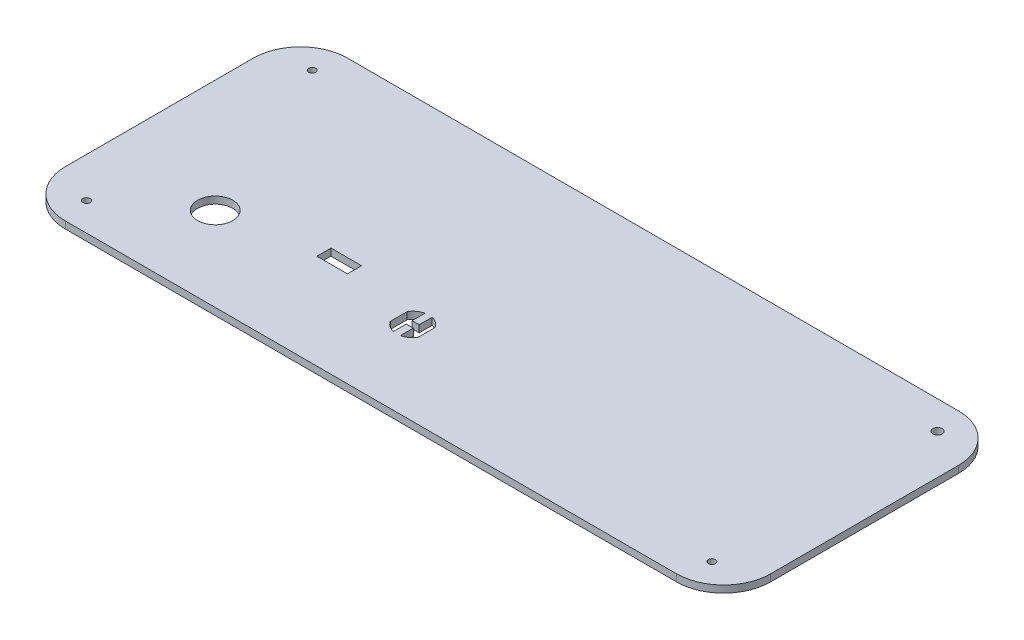
from build123d import *

# Parameters (mm, degrees)
SKETCH_2_W      = 300
SKETCH_2_H      = 120
SKETCH_2_R      = 1.5
SKETCH_2_R_2    = 2
SKETCH_2_R_3    = 7.5
SKETCH_2_W_2    = 13
SKETCH_2_H_2    = 6
EXTRUDE_1_DEPTH = 3
FILLET_1_R      = 20


with BuildPart() as part:
    # Эскиз2 → Бобышка-Вытянуть1 (new body)
    with BuildSketch(Plane(origin=(0, 0, 0), x_dir=(1, 0, 0), z_dir=(0, 1, 0))):
        with Locations((-150, 60)):
            Rectangle(SKETCH_2_W, SKETCH_2_H)
        with Locations((-283, 108)):
            Circle(SKETCH_2_R, mode=Mode.SUBTRACT)
        with Locations((-17, 108)):
            Circle(SKETCH_2_R_2, mode=Mode.SUBTRACT)
        with Locations((-17, 12)):
            Circle(SKETCH_2_R, mode=Mode.SUBTRACT)
        with Locations((-283, 12)):
            Circle(SKETCH_2_R, mode=Mode.SUBTRACT)
        with Locations((-252, 35.746485704)):
            Circle(SKETCH_2_R_3, mode=Mode.SUBTRACT)
        with Locations((-207, 43.496485704)):
            Rectangle(SKETCH_2_W_2, SKETCH_2_H_2, mode=Mode.SUBTRACT)
        with BuildLine():
            Line((-173.9, 39.324194468), (-173.9, 32.16877694))
            ThreePointArc((-173.9, 32.16877694), (-172.022697555, 30.140426091), (-169.5, 29.011502408))
            Line((-169.5, 29.011502408), (-169.5, 34.496485704))
            Line((-169.5, 34.496485704), (-166.5, 34.496485704))
            Line((-166.5, 34.496485704), (-166.5, 29.011502408))
            ThreePointArc((-166.5, 29.011502408), (-163.977302445, 30.140426091), (-162.1, 32.16877694))
            Line((-162.1, 32.16877694), (-162.1, 39.324194468))
            ThreePointArc((-162.1, 39.324194468), (-163.977302445, 41.352545317), (-166.5, 42.481469))
            Line((-166.5, 42.481469), (-166.5, 36.996485704))
            Line((-166.5, 36.996485704), (-169.5, 36.996485704))
            Line((-169.5, 36.996485704), (-169.5, 42.481469))
            ThreePointArc((-169.5, 42.481469), (-172.022697555, 41.352545317), (-173.9, 39.324194468))
        make_face(mode=Mode.SUBTRACT)
    extrude(amount=EXTRUDE_1_DEPTH)

    # Скругление1
    fillet_1_edges = [part.edges().sort_by_distance(p)[0] for p in [
        (0, 1.5, 0),
        (-300, 1.5, 0),
        (-300, 1.5, -120),
        (0, 1.5, -120),
    ]]
    fillet(fillet_1_edges, radius=FILLET_1_R)


solid = part.part
